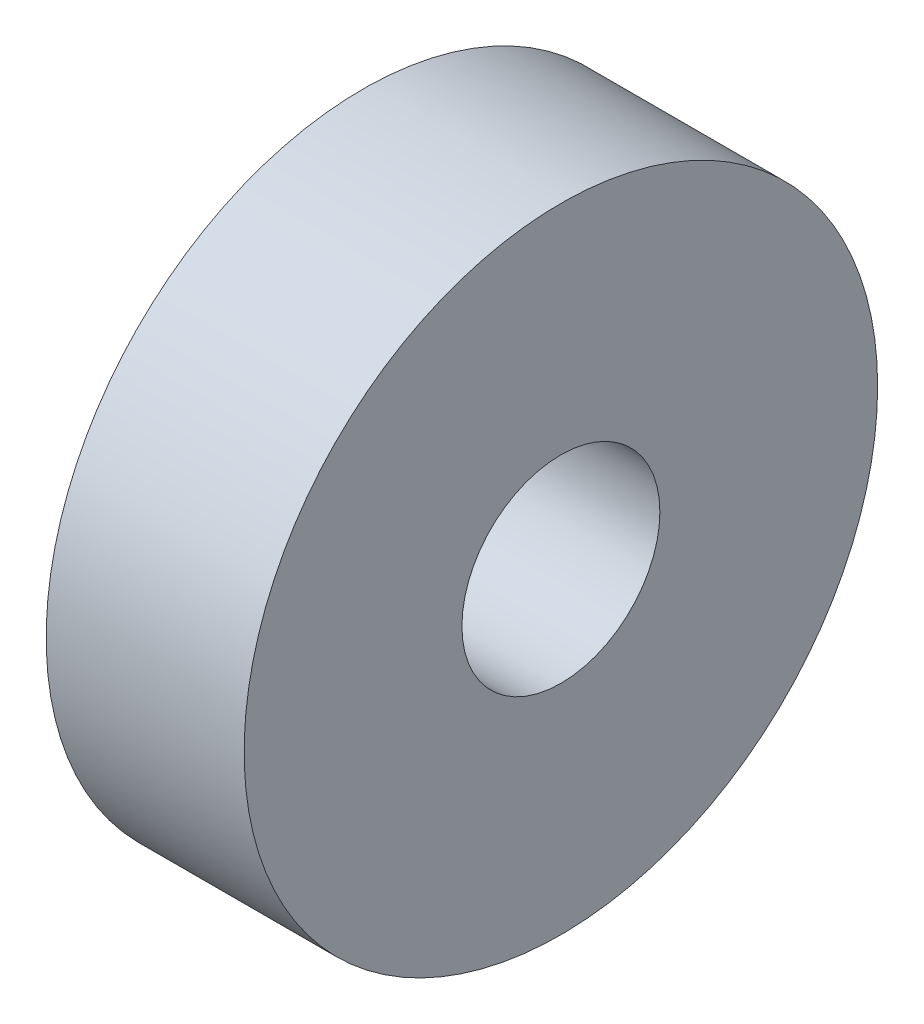
from build123d import *

# Parameters (mm, degrees)
SKETCH1_R           = 8
SKETCH1_R_2         = 2.5
BOSS_EXTRUDE1_DEPTH = 5


with BuildPart() as part:
    # Sketch1 → Boss-Extrude1 (new body)
    with BuildSketch(Plane(origin=(0, 0, 0), x_dir=(0, 0, -1), z_dir=(1, 0, 0))):
        Circle(SKETCH1_R)
        Circle(SKETCH1_R_2, mode=Mode.SUBTRACT)
    extrude(amount=BOSS_EXTRUDE1_DEPTH)


solid = part.part
